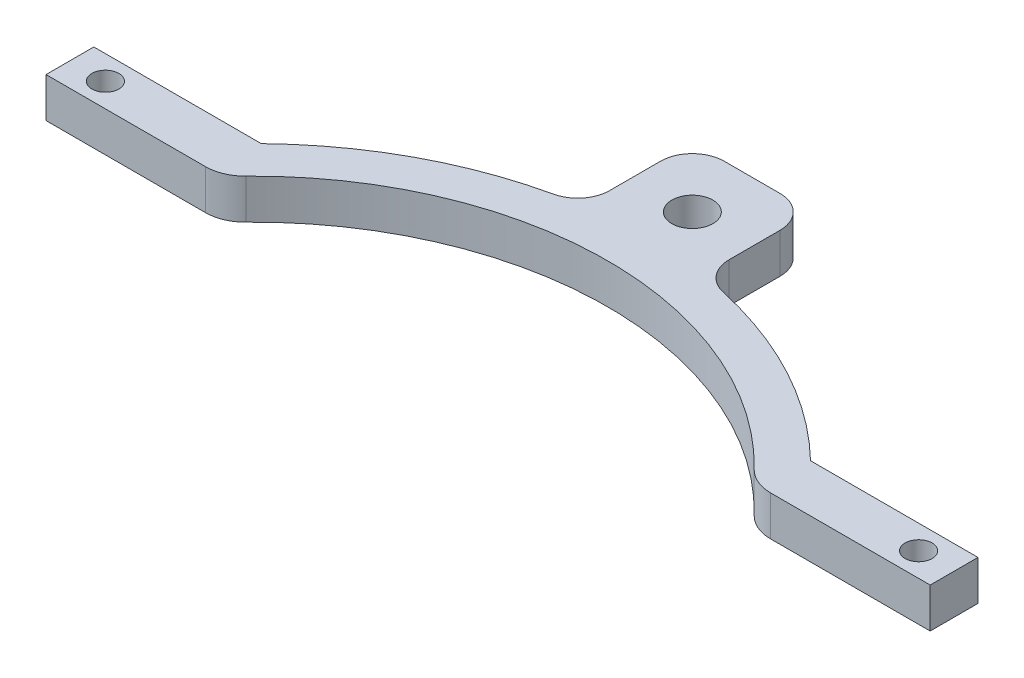
from build123d import *

# Parameters (mm, degrees)
SKETCH1_R           = 62.70625
SKETCH1_R_2         = 56.3626
BOSS_EXTRUDE1_DEPTH = 6.35
SKETCH5_W           = 19.05
SKETCH5_H           = 18.832271031
BOSS_EXTRUDE2_DEPTH = 6.35
FILLET1_R           = 5.08
SKETCH11_R          = 3.2639
CUT_EXTRUDE2_DEPTH  = 7.35
SKETCH17_W          = 169.784888888
SKETCH17_H          = 116.987853086
CUT_EXTRUDE3_DEPTH  = 7.35
FILLET2_R           = 6.35
SKETCH18_R          = 2.15265
BOSS_EXTRUDE4_DEPTH = 6.35


with BuildPart() as part:
    # Sketch1 → Boss-Extrude1 (new body)
    with BuildSketch(Plane(origin=(0, 0, 0), x_dir=(1, 0, 0), z_dir=(0, 1, 0))):
        Circle(SKETCH1_R)
        Circle(SKETCH1_R_2, mode=Mode.SUBTRACT)
    extrude(amount=BOSS_EXTRUDE1_DEPTH)

    # Sketch5 → Boss-Extrude2 (add)
    with BuildSketch(Plane(origin=(0, 6.35, 0), x_dir=(1, 0, 0), z_dir=(0, 1, 0))):
        with Locations((0, 69.958864484)):
            Rectangle(SKETCH5_W, SKETCH5_H)
    extrude(amount=-BOSS_EXTRUDE2_DEPTH)

    # Fillet1
    fillet1_edges = [part.edges().sort_by_distance(p)[0] for p in [
        (9.525, 3.175, -61.978610537),
        (-9.525, 3.175, -61.978610537),
        (9.525, 3.175, -79.375),
        (-9.525, 3.175, -79.375),
    ]]
    fillet(fillet1_edges, radius=FILLET1_R)

    # Sketch11 → Cut-Extrude2 (cut, through all)
    with BuildSketch(Plane.XZ):
        with Locations((0, -69.85)):
            Circle(SKETCH11_R)
    extrude(amount=-CUT_EXTRUDE2_DEPTH, mode=Mode.SUBTRACT)

    # Sketch17 → Cut-Extrude3 (cut, through all)
    with BuildSketch(Plane(origin=(0, 6.35, 0), x_dir=(1, 0, 0), z_dir=(0, 1, 0))):
        with Locations((0, -21.181326543)):
            Rectangle(SKETCH17_W, SKETCH17_H)
    extrude(amount=-CUT_EXTRUDE3_DEPTH, mode=Mode.SUBTRACT)

    # Fillet2
    fillet2_edges = [part.edges().sort_by_distance(p)[0] for p in [
        (-42.243491333, 3.175, -37.3126),
        (42.243491333, 3.175, -37.3126),
    ]]
    fillet(fillet2_edges, radius=FILLET2_R)

    # Sketch18 → Boss-Extrude4 (add)
    with BuildSketch(Plane(origin=(0, 6.35, 0), x_dir=(1, 0, 0), z_dir=(0, 1, 0))):
        Polygon((-50.396861711, 37.3126), (-70.416081127, 37.3126), (-70.416081127, 44.9326), (-43.739401531, 44.9326), align=None)
        with Locations((-64.77, 41.1226)):
            Circle(SKETCH18_R, mode=Mode.SUBTRACT)
        Polygon((50.396861711, 37.3126), (43.739401531, 44.9326), (70.416081127, 44.9326), (70.416081127, 37.3126), align=None)
        with Locations((64.77, 41.1226)):
            Circle(SKETCH18_R, mode=Mode.SUBTRACT)
    extrude(amount=-BOSS_EXTRUDE4_DEPTH)


solid = part.part
